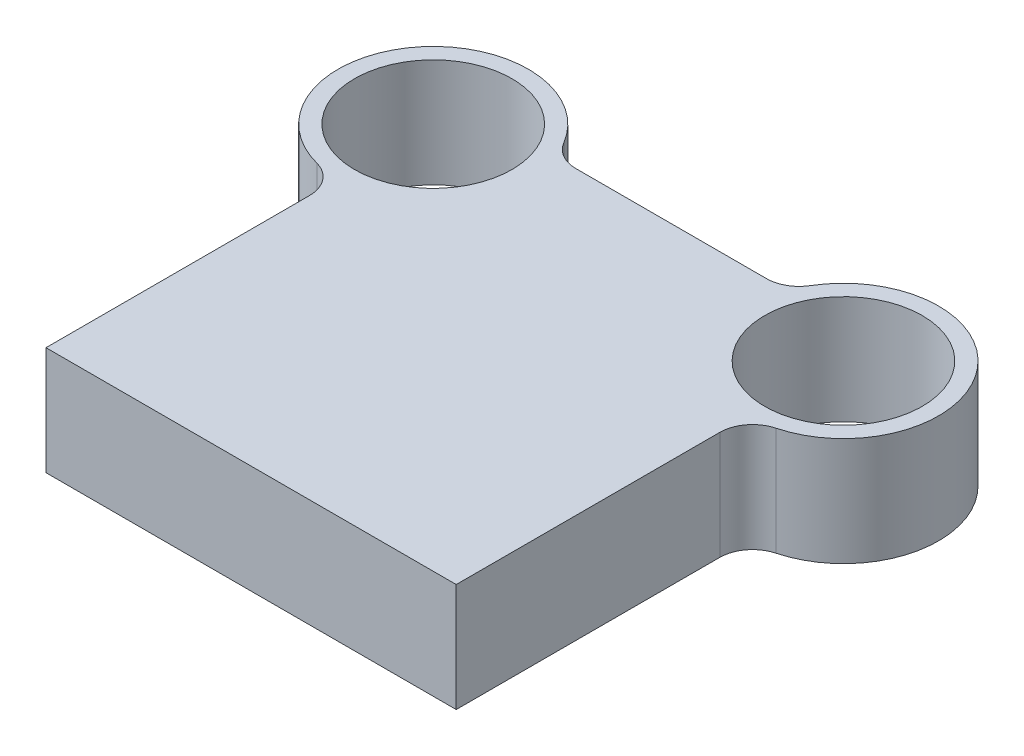
from build123d import *

# Parameters (mm, degrees)
SKETCH1_R           = 24
BOSS_EXTRUDE1_DEPTH = 33
FILLET1_R           = 10


with BuildPart() as part:
    # Sketch1 → Boss-Extrude1 (new body)
    with BuildSketch(Plane(origin=(0, 0, 0), x_dir=(1, 0, 0), z_dir=(0, 1, 0))):
        with BuildLine():
            Line((62.5, 0), (-62.5, 0))
            Line((-62.5, 0), (-62.5, 89))
            ThreePointArc((-62.5, 89), (-86.280243901, 134.598192673), (-35.278684822, 128))
            Line((-35.278684822, 128), (35.278684822, 128))
            ThreePointArc((35.278684822, 128), (86.280243901, 134.598192673), (62.5, 89))
            Line((62.5, 89), (62.5, 0))
        make_face()
        with Locations((-62.5, 118)):
            Circle(SKETCH1_R, mode=Mode.SUBTRACT)
        with Locations((62.5, 118)):
            Circle(SKETCH1_R, mode=Mode.SUBTRACT)
    extrude(amount=BOSS_EXTRUDE1_DEPTH)

    # Fillet1
    fillet1_edges = [part.edges().sort_by_distance(p)[0] for p in [
        (-62.5, 16.5, -89),
        (-35.278684822, 16.5, -128),
        (35.278684822, 16.5, -128),
        (62.5, 16.5, -89),
    ]]
    fillet(fillet1_edges, radius=FILLET1_R)


solid = part.part
